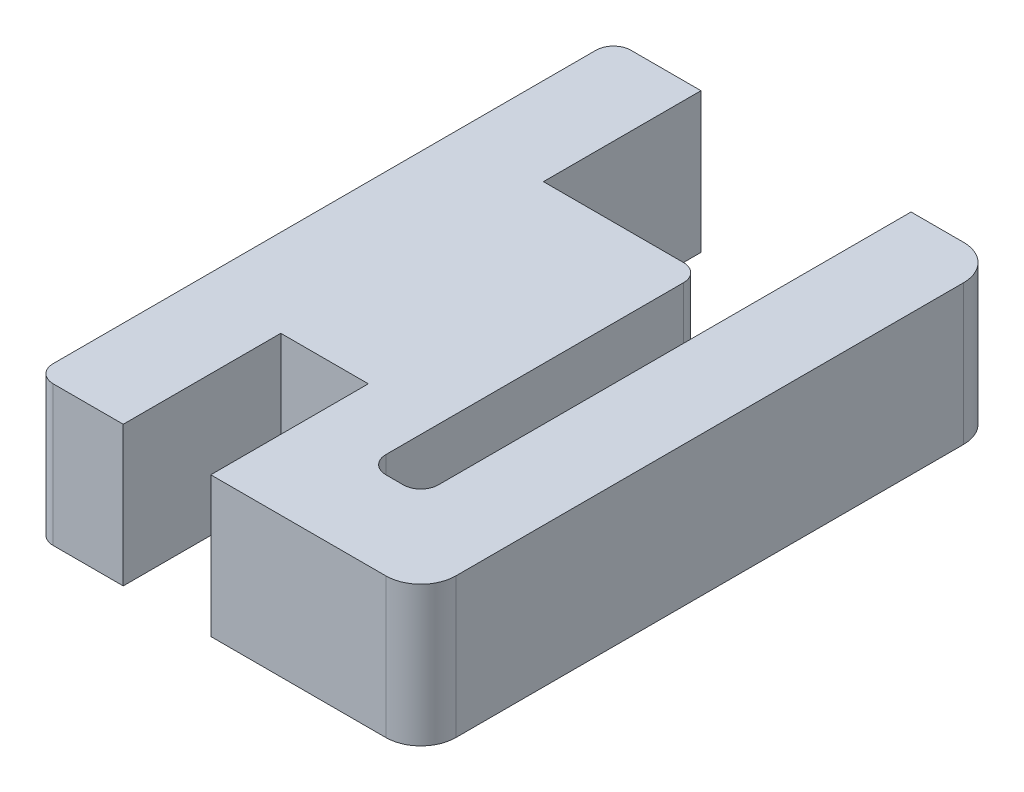
from build123d import *

# Parameters (mm, degrees)
SALIENTE_EXTRUIR1_DEPTH = 4
REDONDEO1_R             = 0.5
REDONDEO2_R             = 1


with BuildPart() as part:
    # Croquis1 → Saliente-Extruir1 (new body)
    with BuildSketch(Plane(origin=(0, 0, 0), x_dir=(1, 0, 0), z_dir=(0, 1, 0))):
        Polygon((8.5, 2.5), (7, 2.5), (7, 12), (2.5, 12), (2.5, 16.5), (0, 16.5), (0, 0), (2.5, 0), (2.5, 4.5), (5, 4.5), (5, 0), (11, 0), (11, 16.5), (8.5, 16.5), align=None)
    extrude(amount=SALIENTE_EXTRUIR1_DEPTH)

    # Redondeo1
    redondeo1_edges = [part.edges().sort_by_distance(p)[0] for p in [
        (8.5, 2, -2.5),
        (0, 2, 0),
        (0, 2, -16.5),
        (7, 2, -12),
        (7, 2, -2.5),
    ]]
    fillet(redondeo1_edges, radius=REDONDEO1_R)

    # Redondeo2
    redondeo2_edges = [part.edges().sort_by_distance(p)[0] for p in [
        (11, 2, -16.5),
        (11, 2, 0),
    ]]
    fillet(redondeo2_edges, radius=REDONDEO2_R)


solid = part.part
